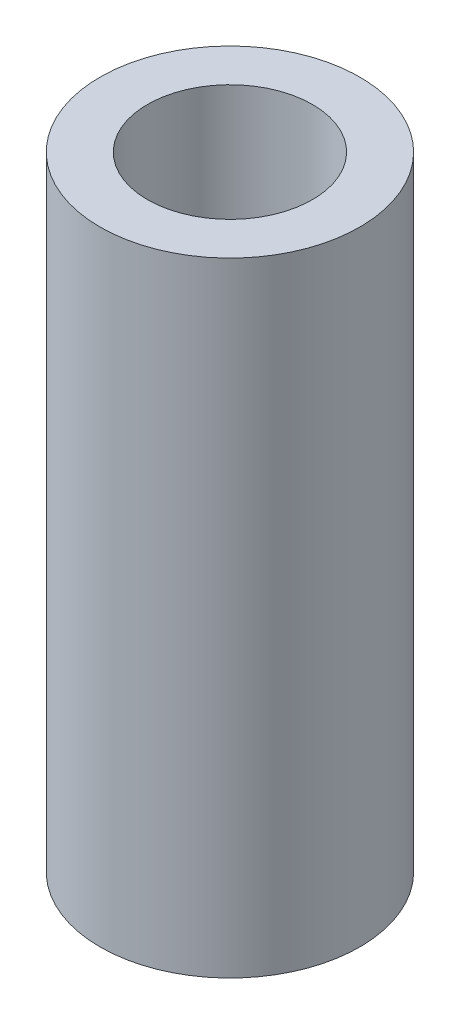
from build123d import *

# Parameters (mm, degrees)
SKETCH2_R               = 3.96875
BOSS_EXTRUDE1_DEPTH     = 19.05
SKETCH3_R               = 2.52095
CUT_EXTRUDE1_DEPTH      = 1
CUT_EXTRUDE1_DEPTH_BACK = 20.05


with BuildPart() as part:
    # Sketch2 → Boss-Extrude1 (new body)
    with BuildSketch(Plane(origin=(0, 0, 0), x_dir=(1, 0, 0), z_dir=(0, 1, 0))):
        Circle(SKETCH2_R)
    extrude(amount=BOSS_EXTRUDE1_DEPTH)

    # Sketch3 → Cut-Extrude1 (cut, two sides)
    with BuildSketch(Plane(origin=(0, 19.05, 0), x_dir=(1, 0, 0), z_dir=(0, 1, 0))) as cut_extrude1_sk:
        Circle(SKETCH3_R)
    extrude(amount=CUT_EXTRUDE1_DEPTH, mode=Mode.SUBTRACT)
    extrude(cut_extrude1_sk.sketch, amount=-CUT_EXTRUDE1_DEPTH_BACK, mode=Mode.SUBTRACT)


solid = part.part
